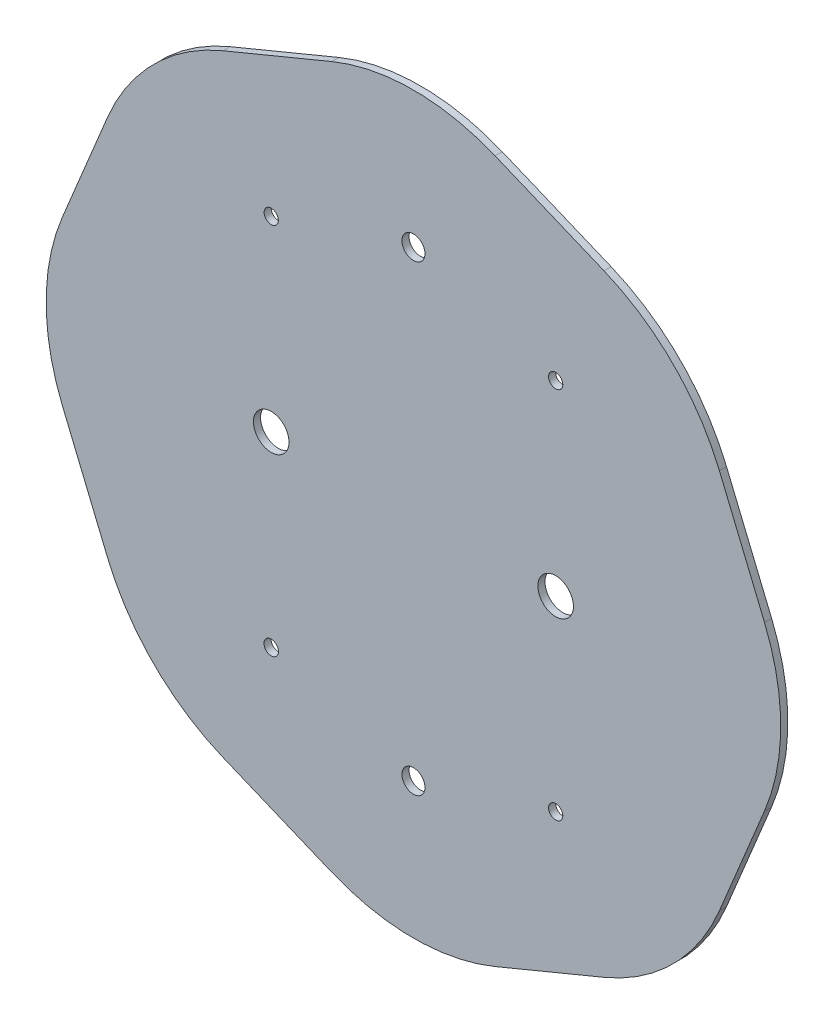
from build123d import *

# Parameters (mm, degrees)
BOSS_EXTRUDE1_DEPTH = 0.2
SKETCH2_R           = 0.323929716
SKETCH2_R_2         = 0.2
SKETCH2_R_3         = 0.203589937
SKETCH2_R_4         = 0.5
CUT_EXTRUDE1_DEPTH  = 1.2


with BuildPart() as part:
    # Sketch1 → Boss-Extrude1 (new body)
    with BuildSketch(Plane.XY):
        with BuildLine():
            Line((-2.296100594, 9.872845996), (-5.357568053, 8.604744654))
            ThreePointArc((-5.357568053, 8.604744654), (-7.304108146, 7.304108146), (-8.604744654, 5.357568053))
            Line((-8.604744654, 5.357568053), (-9.872845996, 2.296100594))
            ThreePointArc((-9.872845996, 2.296100594), (-10.329568801, 0), (-9.872845996, -2.296100594))
            Line((-9.872845996, -2.296100594), (-8.604744654, -5.357568053))
            ThreePointArc((-8.604744654, -5.357568053), (-7.304108146, -7.304108146), (-5.357568053, -8.604744654))
            Line((-5.357568053, -8.604744654), (-2.296100594, -9.872845996))
            ThreePointArc((-2.296100594, -9.872845996), (0, -10.329568801), (2.296100594, -9.872845996))
            Line((2.296100594, -9.872845996), (5.357568053, -8.604744654))
            ThreePointArc((5.357568053, -8.604744654), (7.304108146, -7.304108146), (8.604744654, -5.357568053))
            Line((8.604744654, -5.357568053), (9.872845996, -2.296100594))
            ThreePointArc((9.872845996, -2.296100594), (10.329568801, 0), (9.872845996, 2.296100594))
            Line((9.872845996, 2.296100594), (8.604744654, 5.357568053))
            ThreePointArc((8.604744654, 5.357568053), (7.304108146, 7.304108146), (5.357568053, 8.604744654))
            Line((5.357568053, 8.604744654), (2.296100594, 9.872845996))
            ThreePointArc((2.296100594, 9.872845996), (0, 10.329568801), (-2.296100594, 9.872845996))
        make_face()
    extrude(amount=BOSS_EXTRUDE1_DEPTH)

    # Sketch2 → Cut-Extrude1 (cut, through all)
    with BuildSketch(Plane(origin=(0, 0, 0), x_dir=(-1, 0, 0), z_dir=(0, 0, -1))):
        with Locations((0, -6.5)):
            Circle(SKETCH2_R)
        with Locations((-4, -5.25)):
            Circle(SKETCH2_R_2)
        with Locations((4, -5.25)):
            Circle(SKETCH2_R_3)
        with Locations((4, 5.25)):
            Circle(SKETCH2_R_2)
        with Locations((0, 6.5)):
            Circle(SKETCH2_R)
        with Locations((-4, 5.25)):
            Circle(SKETCH2_R_2)
        with Locations((4, 0)):
            Circle(SKETCH2_R_4)
        with Locations((-4, 0)):
            Circle(SKETCH2_R_4)
    extrude(amount=-CUT_EXTRUDE1_DEPTH, mode=Mode.SUBTRACT)


solid = part.part
